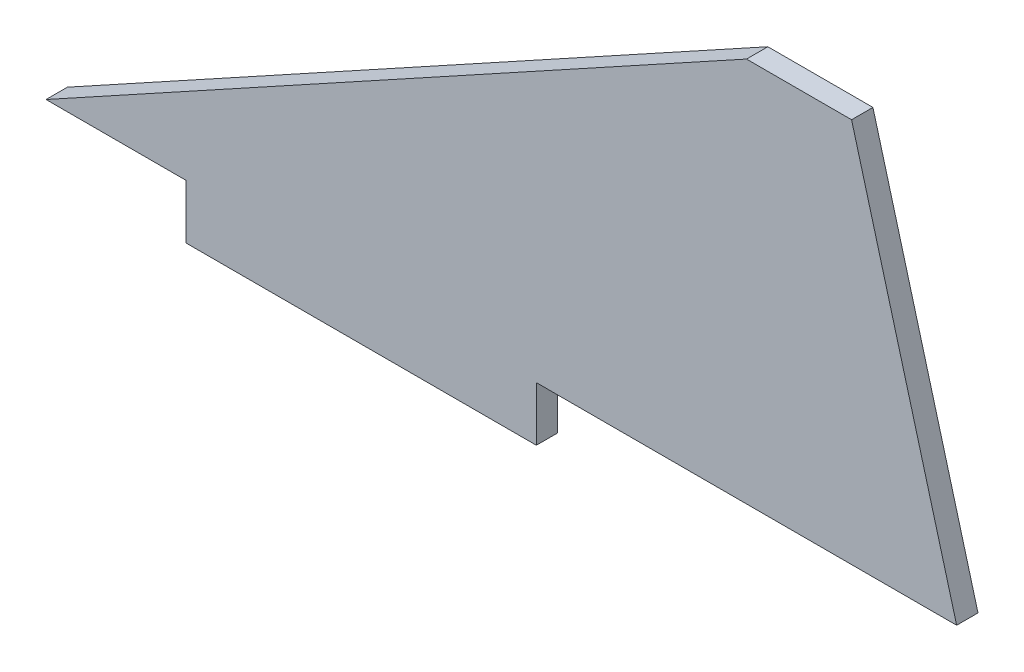
from build123d import *

# Parameters (mm, degrees)
BOSS_EXTRUDE1_DEPTH = 3.048


with BuildPart() as part:
    # Sketch1 → Boss-Extrude1 (new body)
    with BuildSketch(Plane.XY):
        Polygon((0, 0), (20, 0), (20, -7.747), (70, -7.747), (70, 0), (130, 0), (115, 55), (100, 55), align=None)
    extrude(amount=BOSS_EXTRUDE1_DEPTH)


solid = part.part
